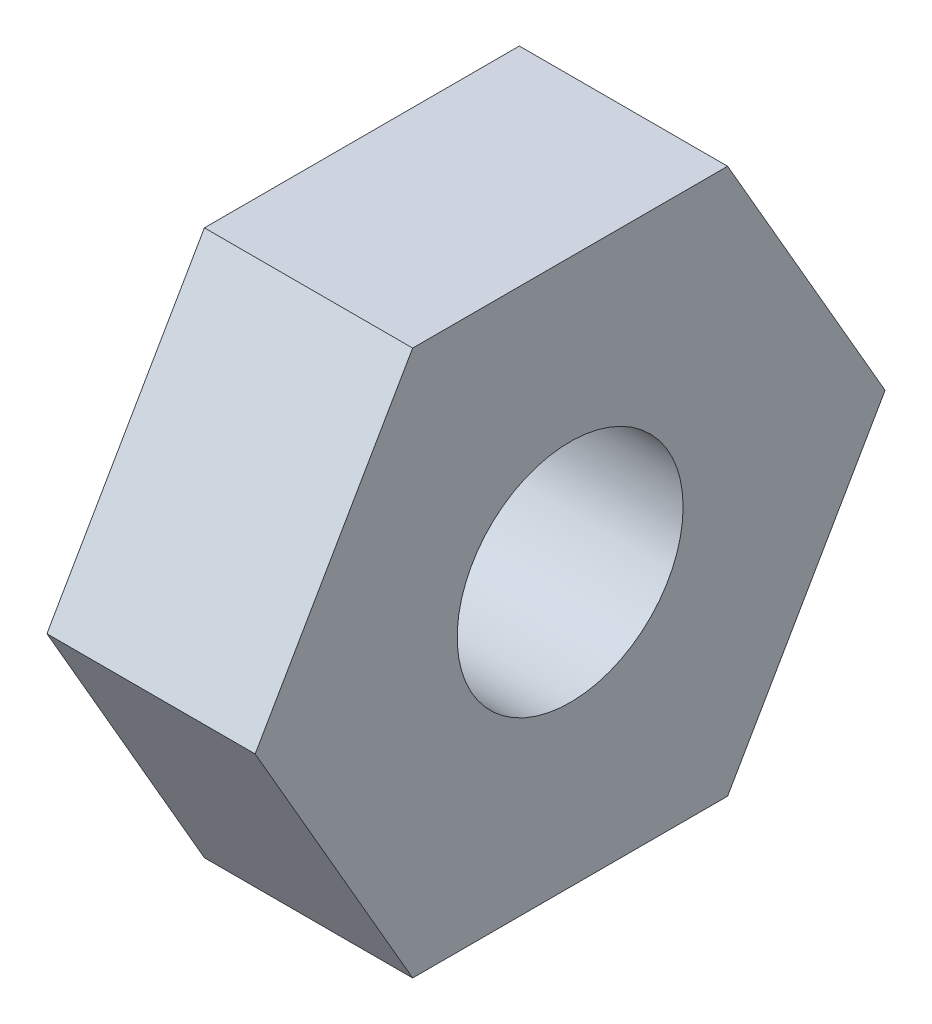
from build123d import *

# Parameters (mm, degrees)
SKETCH1_R           = 2.48
BOSS_EXTRUDE1_DEPTH = 4.572
SKETCH2_R           = 3.81
SKETCH2_R_2         = 2.48
BOSS_EXTRUDE2_DEPTH = 1.016


with BuildPart() as part:
    # Sketch1 → Boss-Extrude1 (new body)
    with BuildSketch(Plane(origin=(0, 0, 0), x_dir=(0, 0, -1), z_dir=(1, 0, 0))):
        Polygon((3.456884737, -5.9875), (6.913769474, 0), (3.456884737, 5.9875), (-3.456884737, 5.9875), (-6.913769474, 0), (-3.456884737, -5.9875), align=None)
        Circle(SKETCH1_R, mode=Mode.SUBTRACT)
    extrude(amount=BOSS_EXTRUDE1_DEPTH)

    # Sketch2 → Boss-Extrude2 (add)
    with BuildSketch(Plane(origin=(0, 0, 0), x_dir=(0, 0, -1), z_dir=(1, 0, 0))):
        Circle(SKETCH2_R)
        Circle(SKETCH2_R_2, mode=Mode.SUBTRACT)
    extrude(amount=-BOSS_EXTRUDE2_DEPTH)


solid = part.part
